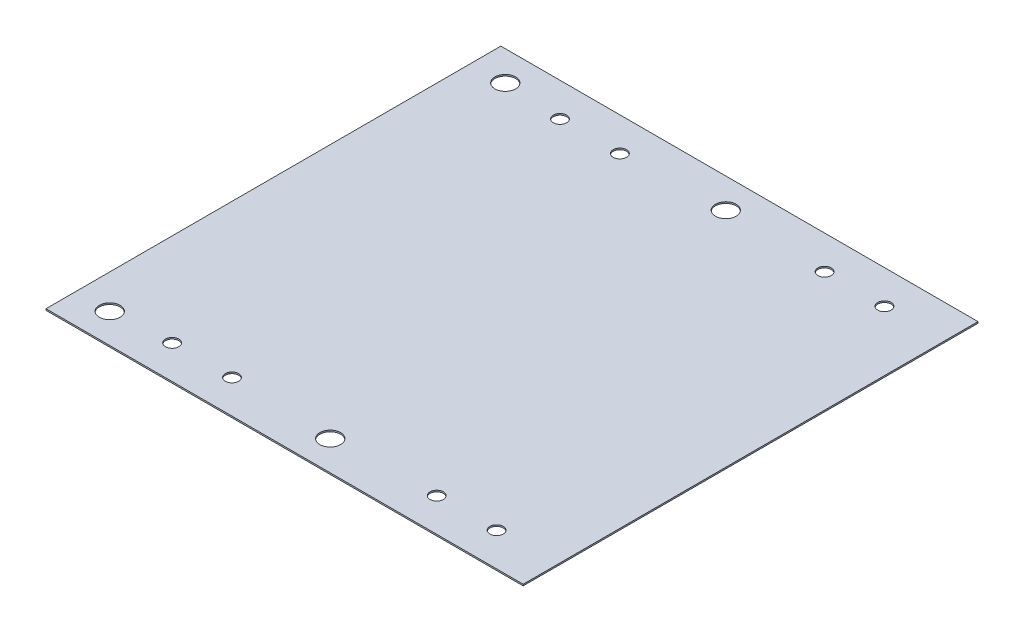
from build123d import *

# Parameters (mm, degrees)
SKETCH1_W           = 80.5
SKETCH1_H           = 76.735
SKETCH1_R           = 1.75
SKETCH1_R_2         = 1.125
BOSS_EXTRUDE1_DEPTH = 0.25


with BuildPart() as part:
    # Sketch1 → Boss-Extrude1 (new body)
    with BuildSketch(Plane(origin=(0, 0, 0), x_dir=(1, 0, 0), z_dir=(0, 1, 0))):
        Rectangle(SKETCH1_W, SKETCH1_H)
        with Locations(Location((-34.5, 33.3675, 0), (0, 0, 270))):  # turned: the seam where the file's is
            Circle(SKETCH1_R, mode=Mode.SUBTRACT)
        with Locations(Location((-24.62, 32.7175, 0), (0, 0, 270))):  # turned: the seam where the file's is
            Circle(SKETCH1_R_2, mode=Mode.SUBTRACT)
        with Locations(Location((-14.52, 32.7175, 0), (0, 0, 270))):  # turned: the seam where the file's is
            Circle(SKETCH1_R_2, mode=Mode.SUBTRACT)
        with Locations(Location((2.7, 33.3675, 0), (0, 0, 270))):  # turned: the seam where the file's is
            Circle(SKETCH1_R, mode=Mode.SUBTRACT)
        with Locations(Location((20.02, 32.7175, 0), (0, 0, 270))):  # turned: the seam where the file's is
            Circle(SKETCH1_R_2, mode=Mode.SUBTRACT)
        with Locations(Location((30.12, 32.7175, 0), (0, 0, 270))):  # turned: the seam where the file's is
            Circle(SKETCH1_R_2, mode=Mode.SUBTRACT)
        with Locations(Location((-34.5, -33.3675, 0), (0, 0, 270))):  # turned: the seam where the file's is
            Circle(SKETCH1_R, mode=Mode.SUBTRACT)
        with Locations(Location((2.7, -33.3675, 0), (0, 0, 270))):  # turned: the seam where the file's is
            Circle(SKETCH1_R, mode=Mode.SUBTRACT)
        with Locations(Location((-24.62, -32.7175, 0), (0, 0, 270))):  # turned: the seam where the file's is
            Circle(SKETCH1_R_2, mode=Mode.SUBTRACT)
        with Locations(Location((-14.52, -32.7175, 0), (0, 0, 270))):  # turned: the seam where the file's is
            Circle(SKETCH1_R_2, mode=Mode.SUBTRACT)
        with Locations(Location((20.02, -32.7175, 0), (0, 0, 270))):  # turned: the seam where the file's is
            Circle(SKETCH1_R_2, mode=Mode.SUBTRACT)
        with Locations(Location((30.12, -32.7175, 0), (0, 0, 270))):  # turned: the seam where the file's is
            Circle(SKETCH1_R_2, mode=Mode.SUBTRACT)
    extrude(amount=BOSS_EXTRUDE1_DEPTH)


solid = part.part
